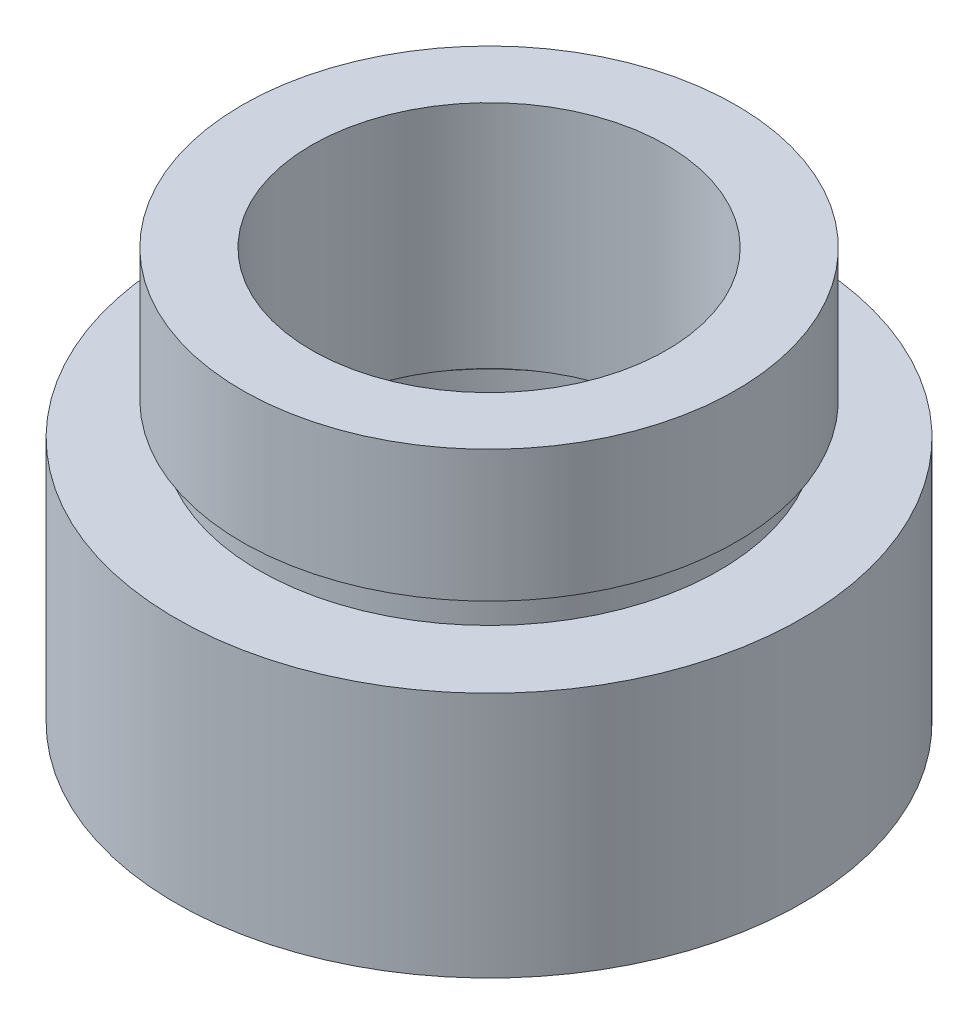
from build123d import *


with BuildPart() as part:
    # 草图1 → 旋转1 (revolve)
    with BuildSketch(Plane.XY, mode=Mode.PRIVATE) as revolve_1_sk:
        Polygon((6.795, 0), (6.795, 4.5), (6.9, 4.5), (6.9, 5.5), (5.4, 5.5), (5.4, 12.5), (7.51, 12.5), (7.51, 8.5), (7, 8.5), (7, 7.5), (9.525, 7.5), (9.525, 0), align=None)
    revolve(revolve_1_sk.sketch.rotate(Axis((0, 16.886018237, 0), (0, -1, 0)), 180), axis=Axis((0, 16.886018237, 0), (0, -1, 0)))  # turned: the seam where the file's is


solid = part.part
